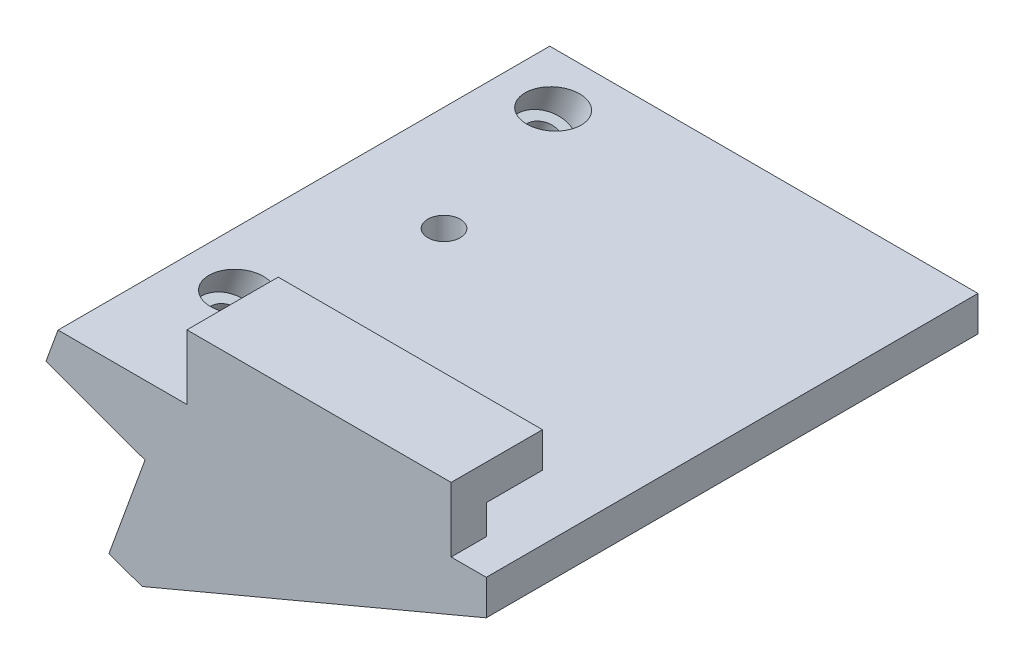
from build123d import *

# Parameters (mm, degrees)
EXTRUDE_1_DEPTH     = 65
SKETCH_4_R          = 2.25
CUT_EXTRUDE_2_DEPTH = 44
CUT_EXTRUDE_START   = -3
SKETCH_5_R          = 3.75
CUT_EXTRUDE_3_DEPTH = 44
EXTRUDE_2_DEPTH     = 5
EXTRUDE_3_DEPTH     = 8
SKETCH_8_R          = 2.3
CUT_EXTRUDE_4_DEPTH = 3.5
CUT_EXTRUDE_6_DEPTH = 14
CUT_EXTRUDE_7_DEPTH = 5


with BuildPart() as part:
    # ｽｹｯﾁ1 → ﾎﾞｽ - 押し出し1 (new body)
    with BuildSketch(Plane.XY):
        Polygon((0, 0), (5.13030215, 14.095389312), (-8.965087162, 19.225691462), (-7.254986445, 23.924154566), (53.707680142, 23.924154566), (53.707680142, 18.924154566), (4.698463104, -1.710100717), align=None)
    extrude(amount=EXTRUDE_1_DEPTH)

    # ｽｹｯﾁ4 → ｶｯﾄ - 押し出し2 (cut)
    with BuildSketch(Plane(origin=(5.13030215, 14.095389312, 0), x_dir=(-0.939692621, 0.342020143, 0), z_dir=(-0.342020143, -0.939692621, 0))):
        with Locations((7.5, -7.5)):
            Circle(SKETCH_4_R)
        with Locations((7.5, -52.5)):
            Circle(SKETCH_4_R)
    extrude(amount=-CUT_EXTRUDE_2_DEPTH, mode=Mode.SUBTRACT)

    # ｽｹｯﾁ5 → ｶｯﾄ - 押し出し3 (cut)
    with BuildSketch(Plane(origin=(5.13030215, 14.095389312, 0), x_dir=(-0.939692621, 0.342020143, 0), z_dir=(-0.342020143, -0.939692621, 0)).offset(CUT_EXTRUDE_START)):
        with Locations((7.5, -52.5)):
            Circle(SKETCH_5_R)
        with Locations((7.5, -7.5)):
            Circle(SKETCH_5_R)
    extrude(amount=-CUT_EXTRUDE_3_DEPTH, mode=Mode.SUBTRACT)

    # ｽｹｯﾁ6 → ﾎﾞｽ - 押し出し2 (add)
    with BuildSketch(Plane(origin=(0, 0, 65), x_dir=(-1, 0, 0), z_dir=(0, 0, -1))):
        Polygon((-53.707680142, 33.124154566), (-53.707680142, 18.924154566), (-4.698463104, -1.710100717), (0, 0), (-5.13030215, 14.095389312), (8.965087162, 19.225691462), (3.90646029, 33.124154566), align=None)
    extrude(amount=-EXTRUDE_2_DEPTH)

    # ｽｹｯﾁ7 → ﾎﾞｽ - 押し出し3 (add)
    with BuildSketch(Plane(origin=(0, 0, 65), x_dir=(-1, 0, 0), z_dir=(0, 0, -1))):
        Polygon((3.90646029, 33.124154566), (5.726311461, 28.124154566), (-53.707680142, 28.124154566), (-53.707680142, 33.124154566), align=None)
    extrude(amount=EXTRUDE_3_DEPTH)

    # ｽｹｯﾁ8 → ｶｯﾄ - 押し出し4 (cut)
    with BuildSketch(Plane(origin=(0, 23.924154566, 0), x_dir=(1, 0, 0), z_dir=(0, 1, 0))):
        with Locations((7.695013555, -30)):
            Circle(SKETCH_8_R)
    extrude(amount=-CUT_EXTRUDE_4_DEPTH, mode=Mode.SUBTRACT)

    # ｽｹｯﾁ10 → ｶｯﾄ - 押し出し6 (cut, through all)
    with BuildSketch(Plane(origin=(0, 0, 57), x_dir=(-1, 0, 0), z_dir=(0, 0, -1))):
        Polygon((7.254986445, 23.924154566), (-11.09353971, 23.924154566), (-11.09353971, 33.124154566), (3.90646029, 33.124154566), align=None)
    extrude(amount=-CUT_EXTRUDE_6_DEPTH, mode=Mode.SUBTRACT)

    # ｽｹｯﾁ11 → ｶｯﾄ - 押し出し7 (cut)
    with BuildSketch(Plane(origin=(53.707680142, 0, 0), x_dir=(0, 0, -1), z_dir=(1, 0, 0))):
        Polygon((-65, 23.924154566), (-70, 23.924154566), (-70, 33.124154566), (-57, 33.124154566), (-57, 28.124154566), (-65, 28.124154566), align=None)
    extrude(amount=-CUT_EXTRUDE_7_DEPTH, mode=Mode.SUBTRACT)


solid = part.part
